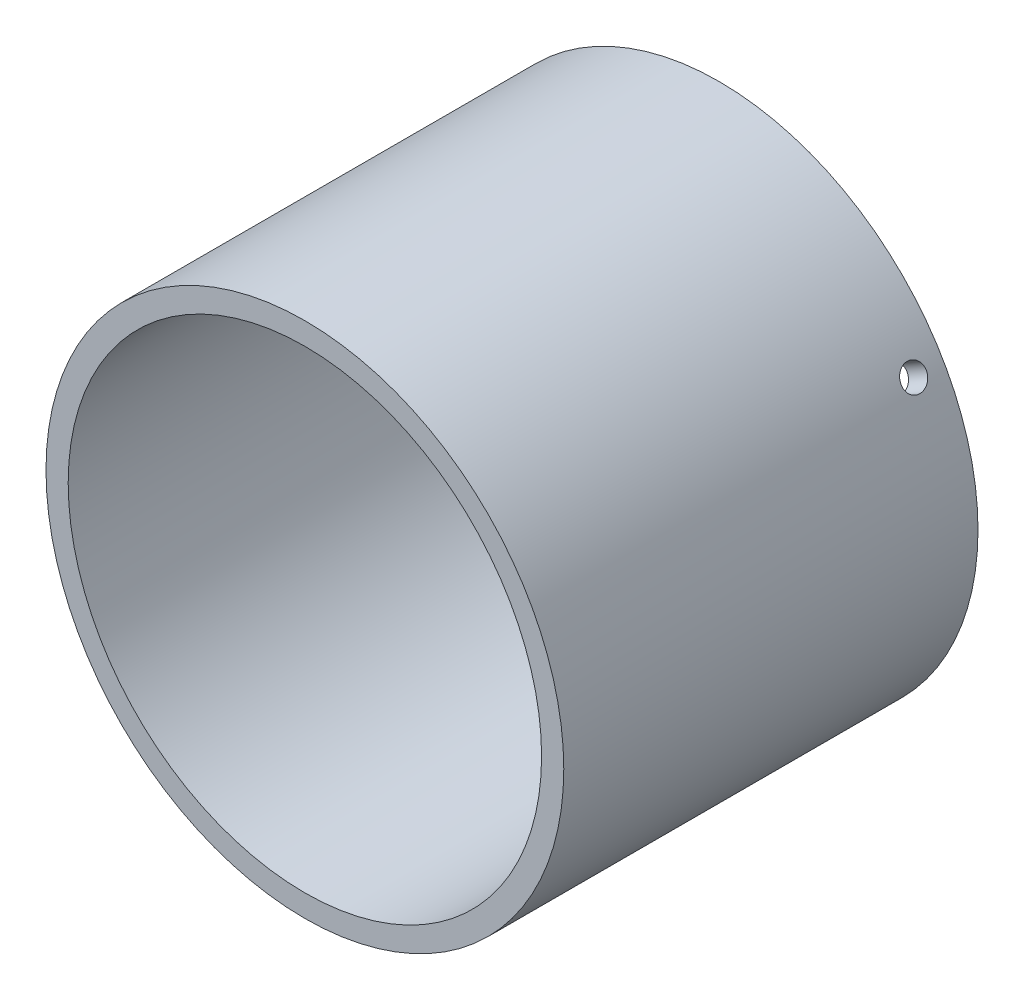
from build123d import *

# Parameters (mm, degrees)
ESQUISSE1_R                  = 35
ESQUISSE1_R_2                = 32
BASE_EXTRUSION_DEPTH         = 56
ESQUISSE2_R                  = 1.7
ENL_V_MAT_EXTRU_1_DEPTH      = 36
R_P_TITION_CIRCULAIRE1_COUNT = 3


with BuildPart() as part:
    # Esquisse1 → Base-Extrusion (new body)
    with BuildSketch(Plane.XY):
        Circle(ESQUISSE1_R)
        Circle(ESQUISSE1_R_2, mode=Mode.SUBTRACT)
    extrude(amount=BASE_EXTRUSION_DEPTH)

    # Esquisse2 → Enlèv. mat.-Extru.1 (cut, through all)
    with BuildSketch(Plane(origin=(0, 0, 0), x_dir=(1, 0, 0), z_dir=(0, 1, 0))):
        with Locations((0, -4)):
            Circle(ESQUISSE2_R)
    enl_v_mat_extru_1 = extrude(amount=-ENL_V_MAT_EXTRU_1_DEPTH, mode=Mode.SUBTRACT)

    # Répétition circulaire1: Enlèv. mat.-Extru.1 ×3 about axis
    r_p_tition_circulaire1_axis = Axis((0, 0, 0), (0, 0, -1))
    for i in range(1, R_P_TITION_CIRCULAIRE1_COUNT):
        add(enl_v_mat_extru_1.rotate(r_p_tition_circulaire1_axis, i * 360 / R_P_TITION_CIRCULAIRE1_COUNT), mode=Mode.SUBTRACT)


solid = part.part
